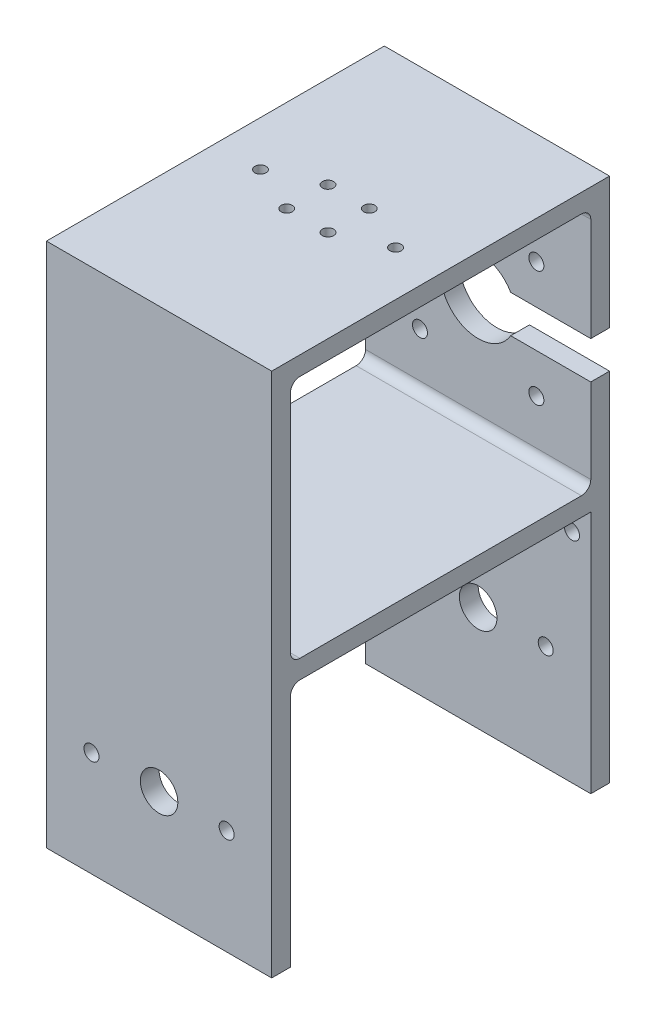
from build123d import *

# Parameters (mm, degrees)
BOSS_EXTRUDE1_DEPTH = 60
SKETCH2_W           = 80
SKETCH2_H           = 65
CUT_EXTRUDE1_DEPTH  = 60
CUT_EXTRUDE2_REACH  = 142
SKETCH3_R           = 1.5
CUT_EXTRUDE3_REACH  = 92
SKETCH4_R           = 5
SKETCH4_R_2         = 10
SKETCH4_R_3         = 2
FILLET1_R           = 2.5
FILLET3_R           = 2.5
FILLET4_R           = 2.5
FILLET5_R           = 2.5
FILLET6_R           = 2.5
SKETCH5_R           = 5
SKETCH5_R_2         = 2
CUT_EXTRUDE4_DEPTH  = 91
CUT_EXTRUDE5_REACH  = 92
SKETCH6_W           = 30
SKETCH6_H           = 10


with BuildPart() as part:
    # Sketch1 → Boss-Extrude1 (new body)
    with BuildSketch(Plane(origin=(0, 0, 0), x_dir=(0, 0, -1), z_dir=(1, 0, 0))):
        Polygon((0, 0), (0, -140), (-5, -140), (-5, -75), (-85, -75), (-85, -140), (-90, -140), (-90, 0), align=None)
    extrude(amount=-BOSS_EXTRUDE1_DEPTH)

    # Sketch2 → Cut-Extrude1 (cut)
    with BuildSketch(Plane(origin=(0, 0, 0), x_dir=(0, 0, -1), z_dir=(1, 0, 0))):
        with Locations((-45, -37.5)):
            Rectangle(SKETCH2_W, SKETCH2_H)
    extrude(amount=-CUT_EXTRUDE1_DEPTH, mode=Mode.SUBTRACT)

    # Sketch3 → Cut-Extrude2 (cut, up to next)
    with BuildSketch(Plane(origin=(0, 0, 0), x_dir=(1, 0, 0), z_dir=(0, 1, 0)), mode=Mode.PRIVATE) as cut_extrude2_sk1:
        with Locations((-24.5, -50.5)):
            Circle(SKETCH3_R)
    cut_extrude2_tool1 = extrude(cut_extrude2_sk1.sketch, amount=-CUT_EXTRUDE2_REACH, mode=Mode.PRIVATE) & part.part
    add(cut_extrude2_tool1.solids().sort_by_distance((-24.5, 0, 50.5))[0], mode=Mode.SUBTRACT)
    # Sketch3 → Cut-Extrude2 (cut, up to next)
    with BuildSketch(Plane(origin=(0, 0, 0), x_dir=(1, 0, 0), z_dir=(0, 1, 0)), mode=Mode.PRIVATE) as cut_extrude2_sk2:
        with Locations((-35.5, -50.5)):
            Circle(SKETCH3_R)
    cut_extrude2_tool2 = extrude(cut_extrude2_sk2.sketch, amount=-CUT_EXTRUDE2_REACH, mode=Mode.PRIVATE) & part.part
    add(cut_extrude2_tool2.solids().sort_by_distance((-35.5, 0, 50.5))[0], mode=Mode.SUBTRACT)
    # Sketch3 → Cut-Extrude2 (cut, up to next)
    with BuildSketch(Plane(origin=(0, 0, 0), x_dir=(1, 0, 0), z_dir=(0, 1, 0)), mode=Mode.PRIVATE) as cut_extrude2_sk3:
        with Locations((-35.5, -39.5)):
            Circle(SKETCH3_R)
    cut_extrude2_tool3 = extrude(cut_extrude2_sk3.sketch, amount=-CUT_EXTRUDE2_REACH, mode=Mode.PRIVATE) & part.part
    add(cut_extrude2_tool3.solids().sort_by_distance((-35.5, 0, 39.5))[0], mode=Mode.SUBTRACT)
    # Sketch3 → Cut-Extrude2 (cut, up to next)
    with BuildSketch(Plane(origin=(0, 0, 0), x_dir=(1, 0, 0), z_dir=(0, 1, 0)), mode=Mode.PRIVATE) as cut_extrude2_sk4:
        with Locations((-24.5, -39.5)):
            Circle(SKETCH3_R)
    cut_extrude2_tool4 = extrude(cut_extrude2_sk4.sketch, amount=-CUT_EXTRUDE2_REACH, mode=Mode.PRIVATE) & part.part
    add(cut_extrude2_tool4.solids().sort_by_distance((-24.5, 0, 39.5))[0], mode=Mode.SUBTRACT)
    # Sketch3 → Cut-Extrude2 (cut, up to next)
    with BuildSketch(Plane(origin=(0, 0, 0), x_dir=(1, 0, 0), z_dir=(0, 1, 0)), mode=Mode.PRIVATE) as cut_extrude2_sk5:
        with Locations((-12, -45)):
            Circle(SKETCH3_R)
    cut_extrude2_tool5 = extrude(cut_extrude2_sk5.sketch, amount=-CUT_EXTRUDE2_REACH, mode=Mode.PRIVATE) & part.part
    add(cut_extrude2_tool5.solids().sort_by_distance((-12, 0, 45))[0], mode=Mode.SUBTRACT)
    # Sketch3 → Cut-Extrude2 (cut, up to next)
    with BuildSketch(Plane(origin=(0, 0, 0), x_dir=(1, 0, 0), z_dir=(0, 1, 0)), mode=Mode.PRIVATE) as cut_extrude2_sk6:
        with Locations((-48, -45)):
            Circle(SKETCH3_R)
    cut_extrude2_tool6 = extrude(cut_extrude2_sk6.sketch, amount=-CUT_EXTRUDE2_REACH, mode=Mode.PRIVATE) & part.part
    add(cut_extrude2_tool6.solids().sort_by_distance((-48, 0, 45))[0], mode=Mode.SUBTRACT)

    # Sketch4 → Cut-Extrude3 (cut, up to next)
    with BuildSketch(Plane.XY, mode=Mode.PRIVATE) as cut_extrude3_sk1:
        with Locations((-30, -112)):
            Circle(SKETCH4_R)
    cut_extrude3_tool1 = extrude(cut_extrude3_sk1.sketch, amount=CUT_EXTRUDE3_REACH, mode=Mode.PRIVATE) & part.part
    add(cut_extrude3_tool1.solids().sort_by_distance((-30, -112, 0))[0], mode=Mode.SUBTRACT)
    # Sketch4 → Cut-Extrude3 (cut, up to next)
    with BuildSketch(Plane.XY, mode=Mode.PRIVATE) as cut_extrude3_sk2:
        with Locations((-30, -40)):
            Circle(SKETCH4_R_2)
    cut_extrude3_tool2 = extrude(cut_extrude3_sk2.sketch, amount=CUT_EXTRUDE3_REACH, mode=Mode.PRIVATE) & part.part
    add(cut_extrude3_tool2.solids().sort_by_distance((-30, -40, 0))[0], mode=Mode.SUBTRACT)
    # Sketch4 → Cut-Extrude3 (cut, up to next)
    with BuildSketch(Plane.XY, mode=Mode.PRIVATE) as cut_extrude3_sk3:
        with Locations((-5, -82)):
            Circle(SKETCH4_R_3)
    cut_extrude3_tool3 = extrude(cut_extrude3_sk3.sketch, amount=CUT_EXTRUDE3_REACH, mode=Mode.PRIVATE) & part.part
    add(cut_extrude3_tool3.solids().sort_by_distance((-5, -82, 0))[0], mode=Mode.SUBTRACT)
    # Sketch4 → Cut-Extrude3 (cut, up to next)
    with BuildSketch(Plane.XY, mode=Mode.PRIVATE) as cut_extrude3_sk4:
        with Locations((-55, -82)):
            Circle(SKETCH4_R_3)
    cut_extrude3_tool4 = extrude(cut_extrude3_sk4.sketch, amount=CUT_EXTRUDE3_REACH, mode=Mode.PRIVATE) & part.part
    add(cut_extrude3_tool4.solids().sort_by_distance((-55, -82, 0))[0], mode=Mode.SUBTRACT)
    # Sketch4 → Cut-Extrude3 (cut, up to next)
    with BuildSketch(Plane.XY, mode=Mode.PRIVATE) as cut_extrude3_sk5:
        with Locations((-14.5, -24.5)):
            Circle(SKETCH4_R_3)
    cut_extrude3_tool5 = extrude(cut_extrude3_sk5.sketch, amount=CUT_EXTRUDE3_REACH, mode=Mode.PRIVATE) & part.part
    add(cut_extrude3_tool5.solids().sort_by_distance((-14.5, -24.5, 0))[0], mode=Mode.SUBTRACT)
    # Sketch4 → Cut-Extrude3 (cut, up to next)
    with BuildSketch(Plane.XY, mode=Mode.PRIVATE) as cut_extrude3_sk6:
        with Locations((-45.5, -24.5)):
            Circle(SKETCH4_R_3)
    cut_extrude3_tool6 = extrude(cut_extrude3_sk6.sketch, amount=CUT_EXTRUDE3_REACH, mode=Mode.PRIVATE) & part.part
    add(cut_extrude3_tool6.solids().sort_by_distance((-45.5, -24.5, 0))[0], mode=Mode.SUBTRACT)
    # Sketch4 → Cut-Extrude3 (cut, up to next)
    with BuildSketch(Plane.XY, mode=Mode.PRIVATE) as cut_extrude3_sk7:
        with Locations((-45.5, -55.5)):
            Circle(SKETCH4_R_3)
    cut_extrude3_tool7 = extrude(cut_extrude3_sk7.sketch, amount=CUT_EXTRUDE3_REACH, mode=Mode.PRIVATE) & part.part
    add(cut_extrude3_tool7.solids().sort_by_distance((-45.5, -55.5, 0))[0], mode=Mode.SUBTRACT)
    # Sketch4 → Cut-Extrude3 (cut, up to next)
    with BuildSketch(Plane.XY, mode=Mode.PRIVATE) as cut_extrude3_sk8:
        with Locations((-14.5, -55.5)):
            Circle(SKETCH4_R_3)
    cut_extrude3_tool8 = extrude(cut_extrude3_sk8.sketch, amount=CUT_EXTRUDE3_REACH, mode=Mode.PRIVATE) & part.part
    add(cut_extrude3_tool8.solids().sort_by_distance((-14.5, -55.5, 0))[0], mode=Mode.SUBTRACT)

    # Fillet1
    fillet1_edges = [part.edges().sort_by_distance(p)[0] for p in [
        (-30, -75, 85),
    ]]
    fillet(fillet1_edges, radius=FILLET1_R)

    # Fillet3
    fillet3_edges = [part.edges().sort_by_distance(p)[0] for p in [
        (-30, -70, 85),
    ]]
    fillet(fillet3_edges, radius=FILLET3_R)

    # Fillet4
    fillet4_edges = [part.edges().sort_by_distance(p)[0] for p in [
        (-30, -70, 5),
    ]]
    fillet(fillet4_edges, radius=FILLET4_R)

    # Fillet5
    fillet5_edges = [part.edges().sort_by_distance(p)[0] for p in [
        (-30, -5, 5),
    ]]
    fillet(fillet5_edges, radius=FILLET5_R)

    # Fillet6
    fillet6_edges = [part.edges().sort_by_distance(p)[0] for p in [
        (-30, -5, 85),
    ]]
    fillet(fillet6_edges, radius=FILLET6_R)

    # Sketch5 → Cut-Extrude4 (cut, through all)
    with BuildSketch(Plane.XY.offset(90)):
        with Locations((-30, -112)):
            Circle(SKETCH5_R)
        with Locations((-12, -112)):
            Circle(SKETCH5_R_2)
        with Locations((-48, -112)):
            Circle(SKETCH5_R_2)
    extrude(amount=-CUT_EXTRUDE4_DEPTH, mode=Mode.SUBTRACT)

    # Sketch6 → Cut-Extrude5 (cut, up to next)
    with BuildSketch(Plane(origin=(0, 0, 0), x_dir=(-1, 0, 0), z_dir=(0, 0, -1)), mode=Mode.PRIVATE) as cut_extrude5_sk1:
        with Locations((15, -40)):
            Rectangle(SKETCH6_W, SKETCH6_H)
    cut_extrude5_tool1 = extrude(cut_extrude5_sk1.sketch, amount=-CUT_EXTRUDE5_REACH, mode=Mode.PRIVATE) & part.part
    add(cut_extrude5_tool1.solids().sort_by_distance((-15, -40, 0))[0], mode=Mode.SUBTRACT)


solid = part.part
